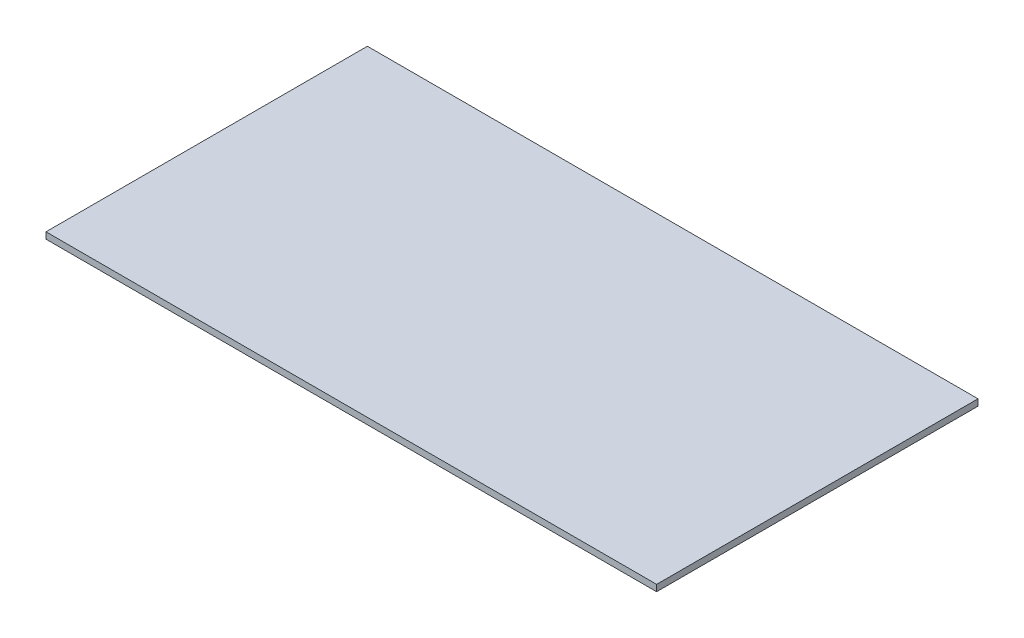
from build123d import *

# Parameters (mm, degrees)
SKETCH1_W           = 95
SKETCH1_H           = 50
BOSS_EXTRUDE1_DEPTH = 0.5


with BuildPart() as part:
    # Sketch1 → Boss-Extrude1 (new body, symmetric)
    with BuildSketch(Plane(origin=(0, 0, 0), x_dir=(1, 0, 0), z_dir=(0, 1, 0))):
        Rectangle(SKETCH1_W, SKETCH1_H)
    extrude(amount=BOSS_EXTRUDE1_DEPTH, both=True)


solid = part.part
